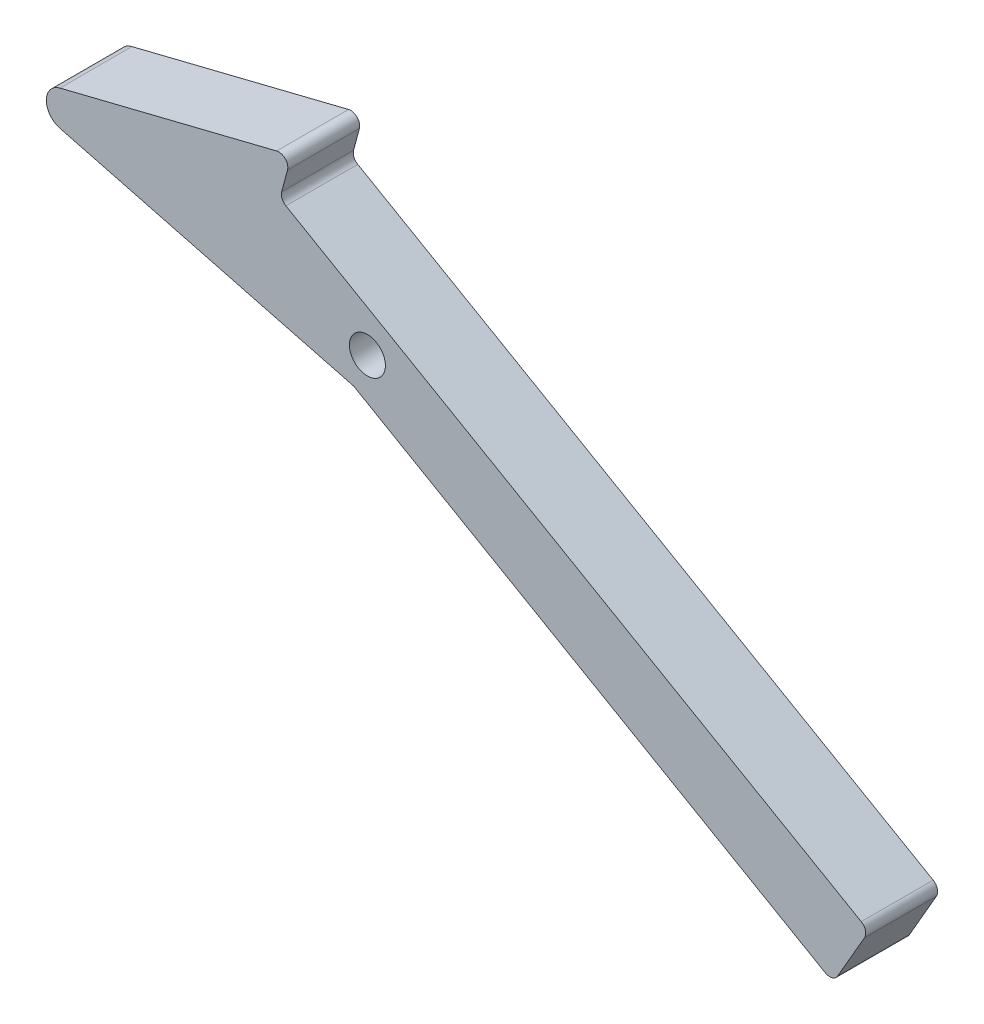
from build123d import *

# Parameters (mm, degrees)
BOSS_EXTRUDE1_DEPTH      = 3.175
BOSS_EXTRUDE1_DEPTH_BACK = 3.175
SKETCH1_R                = 1.5875
FILLET1_R                = 0.79375


with BuildPart() as part:
    # Sketch1 → Boss-Extrude1 (new, two sides: drawn at the far end of the back side and taken through both)
    with BuildSketch(Plane.XY.offset(-BOSS_EXTRUDE1_DEPTH_BACK)):
        with BuildLine():
            Line((-7.728108964, 8.128), (-6.707222541, 11.938))
            Line((-6.707222541, 11.938), (-27.145240318, 6.858))
            ThreePointArc((-27.145240318, 6.858), (-28.349785751, 5.325893193), (-27.161747679, 3.780950957))
            Line((-27.161747679, 3.780950957), (-1.215078314, -2.964648418))
            Line((-1.215078314, -2.964648418), (41.117892306, -27.405600401))
            Line((41.117892306, -27.405600401), (44.292892306, -21.906339087))
            Line((44.292892306, -21.906339087), (-7.728108964, 8.128))
        make_face()
        Circle(SKETCH1_R, mode=Mode.SUBTRACT)
    extrude(amount=BOSS_EXTRUDE1_DEPTH + BOSS_EXTRUDE1_DEPTH_BACK)

    # Fillet1
    fillet1_edges = [part.edges().sort_by_distance(p)[0] for p in [
        (44.292892306, -21.906339087, 0),
        (41.117892306, -27.405600401, 0),
        (-7.728108964, 8.128, 0),
        (-6.707222541, 11.938, 0),
    ]]
    fillet(fillet1_edges, radius=FILLET1_R)


solid = part.part
